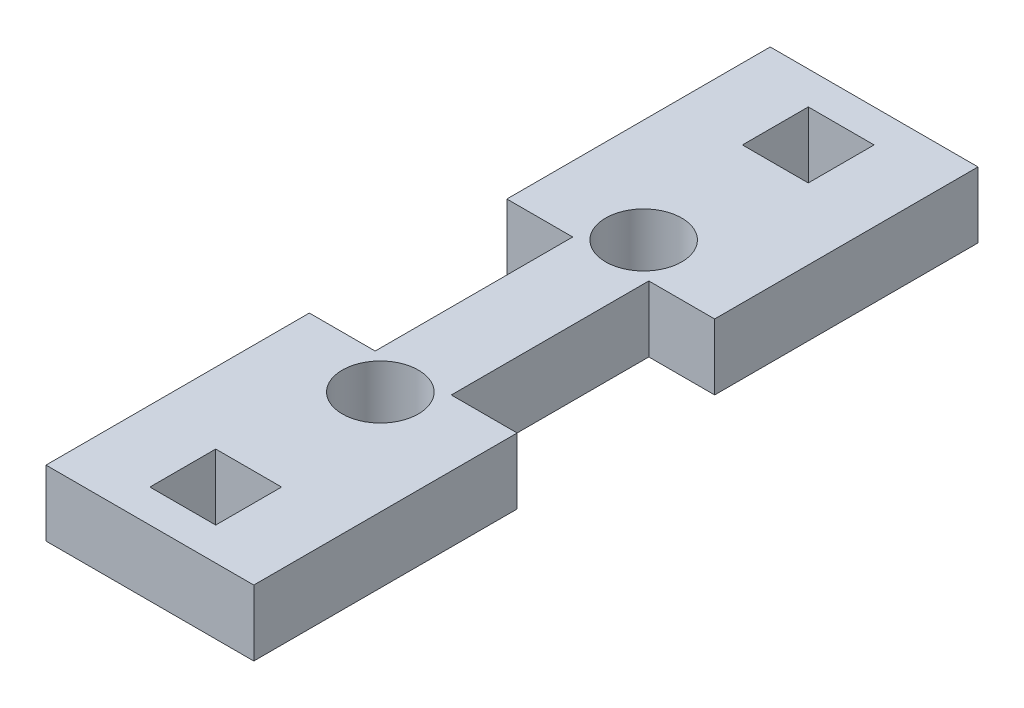
from build123d import *

# Parameters (mm, degrees)
SKETCH1_W           = 6.35
SKETCH1_H           = 6.35
SKETCH1_R           = 3.6703
BOSS_EXTRUDE1_DEPTH = 6.35


with BuildPart() as part:
    # Sketch1 → Boss-Extrude1 (new body)
    with BuildSketch(Plane(origin=(0, 0, 0), x_dir=(1, 0, 0), z_dir=(0, 1, 0))):
        Polygon((0, 25.4), (0, 0), (20.0406, 0), (20.0406, 25.4), (13.6906, 25.4), (13.6906, 44.45), (20.0406, 44.45), (20.0406, 69.85), (0, 69.85), (0, 44.45), (6.35, 44.45), (6.35, 25.4), align=None)
        with Locations((10.0203, 6.35)):
            Rectangle(SKETCH1_W, SKETCH1_H, mode=Mode.SUBTRACT)
        with Locations((10.0203, 22.225)):
            Circle(SKETCH1_R, mode=Mode.SUBTRACT)
        with Locations((10.0203, 63.5)):
            Rectangle(SKETCH1_W, SKETCH1_H, mode=Mode.SUBTRACT)
        with Locations((10.0203, 47.625)):
            Circle(SKETCH1_R, mode=Mode.SUBTRACT)
    extrude(amount=BOSS_EXTRUDE1_DEPTH)


solid = part.part
